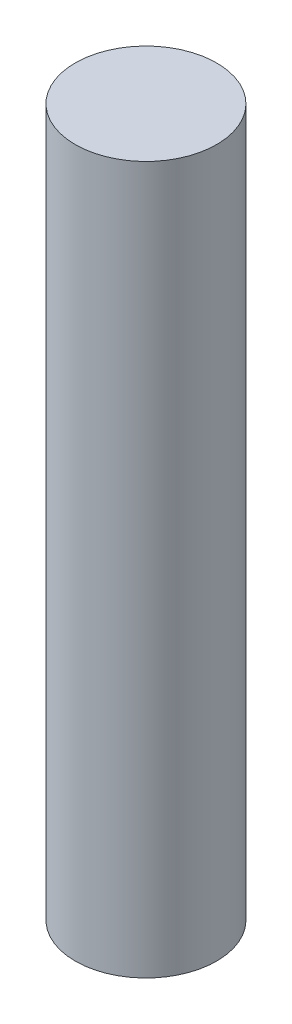
from build123d import *

# Parameters (mm, degrees)
SKETCH1_R           = 5
BOSS_EXTRUDE1_DEPTH = 50


with BuildPart() as part:
    # Sketch1 → Boss-Extrude1 (new body)
    with BuildSketch(Plane(origin=(0, 0, 0), x_dir=(1, 0, 0), z_dir=(0, 1, 0))):
        Circle(SKETCH1_R)
    extrude(amount=BOSS_EXTRUDE1_DEPTH)


solid = part.part
